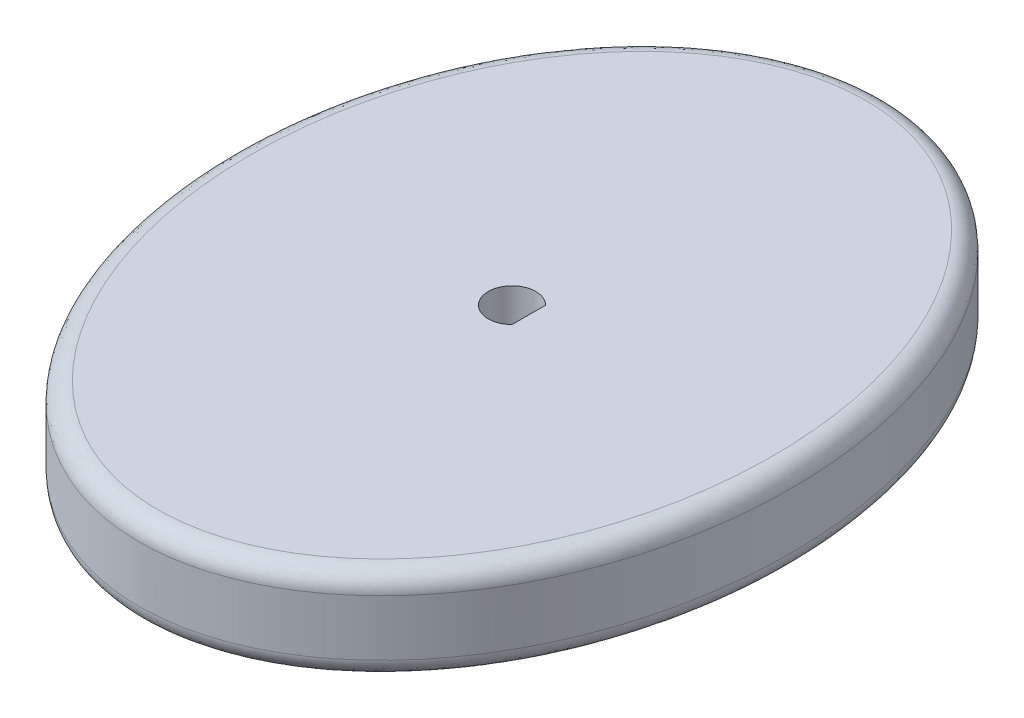
from build123d import *

# Parameters (mm, degrees)
SKETCH2_RX  = 25.4
SKETCH2_RY  = 19.05
CRANK_DEPTH = 6.35
FILLET_2_R  = 1.27


with BuildPart() as part:
    # Sketch2 → Crank (new body)
    with BuildSketch(Plane(origin=(0, 0, 0), x_dir=(1, 0, 0), z_dir=(0, 1, 0))):
        with Locations(Location((0, 0), (0, 0, 90))):
            Ellipse(SKETCH2_RX, SKETCH2_RY)
        with BuildLine():
            Line((1.143, -1.146961884), (1.143, 1.146961884))
            ThreePointArc((1.143, 1.146961884), (-1.61925, 0), (1.143, -1.146961884))
        make_face(mode=Mode.SUBTRACT)
    extrude(amount=CRANK_DEPTH)

    # Fillet 2
    fillet_2_edges = [part.edges().sort_by_distance(p)[0] for p in [
        (0.006668232, 0, 25.399998444),
        (0.006668232, 6.35, 25.399998444),
    ]]
    fillet(fillet_2_edges, radius=FILLET_2_R)


solid = part.part
